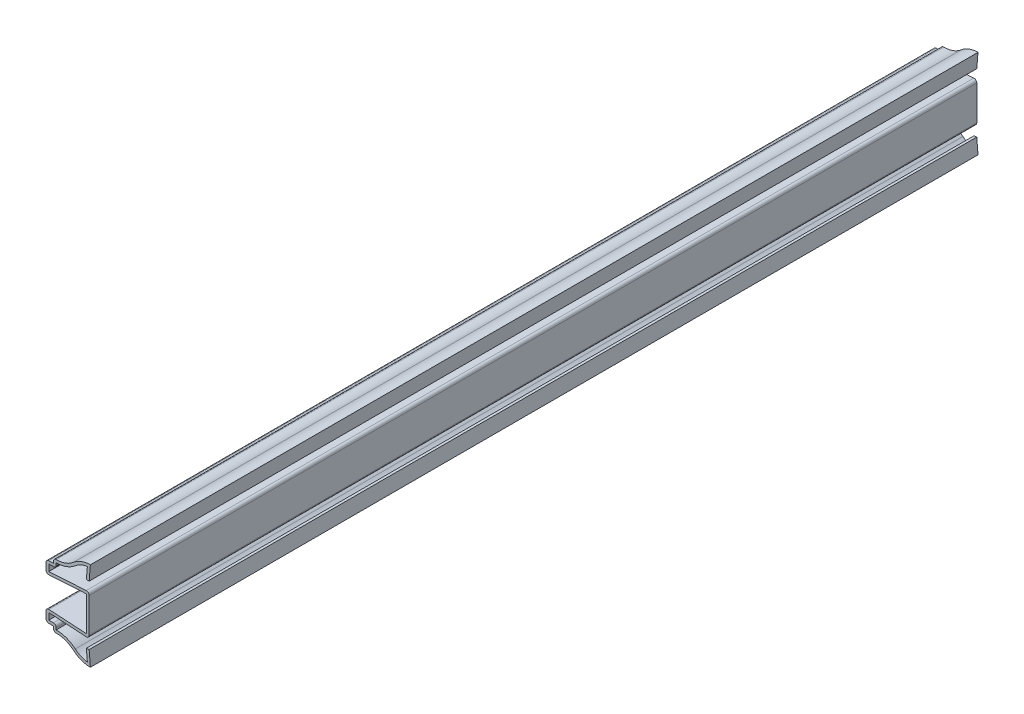
from build123d import *

# Parameters (mm, degrees)
EXTRUDE_THIN1_DEPTH = 285.75
FILLET1_R           = 0.889


with BuildPart() as part:
    # Sketch1 → Extrude-Thin1 (new body)
    with BuildSketch(Plane.XY):
        with BuildLine():
            Line((-0.396875, -9.525), (0, -14.2875))
            ThreePointArc((0, -14.2875), (-2.898897336, -13.767099717), (-5.435779046, -12.270886692))
            ThreePointArc((-5.435779046, -12.270886692), (-8.464256404, -10.6095065), (-11.90625, -10.31875))
            Line((-11.90625, -10.31875), (-11.90625, -8.73125))
            Line((-11.90625, -8.73125), (-14.2875, -8.73125))
            Line((-14.2875, -8.73125), (-14.2875, -4.7625))
            Line((-14.2875, -4.7625), (-1.285875, -5.55625))
            Line((-1.285875, -5.55625), (-1.285875, 5.55625))
            Line((-1.285875, 5.55625), (-14.2875, 4.7625))
            Line((-14.2875, 4.7625), (-14.2875, 8.73125))
            Line((-14.2875, 8.73125), (-11.90625, 8.73125))
            Line((-11.90625, 8.73125), (-11.90625, 10.31875))
            ThreePointArc((-11.90625, 10.31875), (-8.464256404, 10.6095065), (-5.435779046, 12.270886692))
            ThreePointArc((-5.435779046, 12.270886692), (-2.898897336, 13.767099717), (0, 14.2875))
            Line((0, 14.2875), (-0.396875, 9.525))
            Line((-0.396875, 9.525), (-1.282804179, 9.598827432))
            Line((-1.282804179, 9.598827432), (-0.971469005, 13.334849518))
            ThreePointArc((-0.971469005, 13.334849518), (-3.040522473, 12.749361604), (-4.855962615, 11.596992112))
            ThreePointArc((-4.855962615, 11.596992112), (-7.731844672, 9.916114382), (-11.01725, 9.366424127))
            Line((-11.01725, 9.366424127), (-11.01725, 7.84225))
            Line((-11.01725, 7.84225), (-13.3985, 7.84225))
            Line((-13.3985, 7.84225), (-13.3985, 5.707428664))
            Line((-13.3985, 5.707428664), (-0.396875, 6.501178664))
            Line((-0.396875, 6.501178664), (-0.396875, -6.501178664))
            Line((-0.396875, -6.501178664), (-13.3985, -5.707428664))
            Line((-13.3985, -5.707428664), (-13.3985, -7.84225))
            Line((-13.3985, -7.84225), (-11.01725, -7.84225))
            Line((-11.01725, -7.84225), (-11.01725, -9.366424127))
            ThreePointArc((-11.01725, -9.366424127), (-7.731844672, -9.916114382), (-4.855962615, -11.596992112))
            ThreePointArc((-4.855962615, -11.596992112), (-3.040522473, -12.749361604), (-0.971469005, -13.334849518))
            Line((-0.971469005, -13.334849518), (-1.282804179, -9.598827432))
            Line((-1.282804179, -9.598827432), (-0.396875, -9.525))
        make_face()
    extrude(amount=-EXTRUDE_THIN1_DEPTH)

    # Fillet1
    fillet1_edges = [part.edges().sort_by_distance(p)[0] for p in [
        (-11.90625, -10.31875, -142.875),
        (-14.2875, -8.73125, -142.875),
        (-14.2875, -4.7625, -142.875),
        (-14.2875, 4.7625, -142.875),
        (-14.2875, 8.73125, -142.875),
        (-11.90625, 10.31875, -142.875),
        (-11.01725, 7.84225, -142.875),
        (-0.396875, 6.501178664, -142.875),
        (-0.396875, -6.501178664, -142.875),
        (-11.01725, -7.84225, -142.875),
    ]]
    fillet(fillet1_edges, radius=FILLET1_R)


solid = part.part
